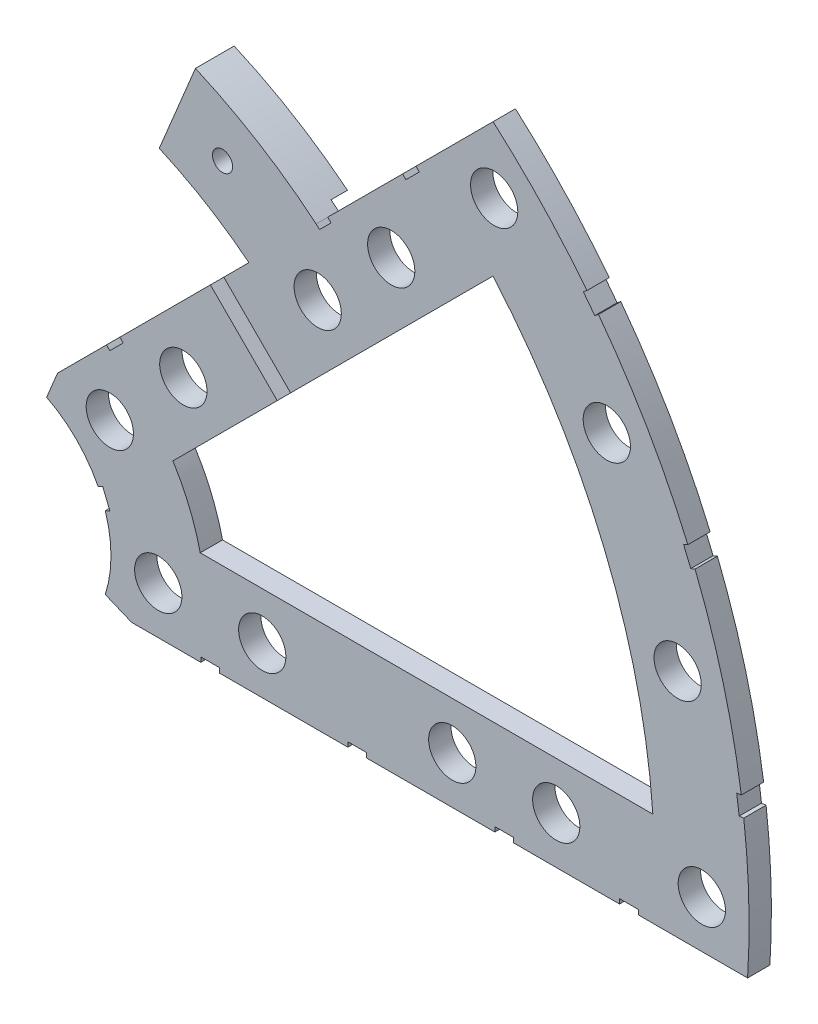
from build123d import *

# Parameters (mm, degrees)
BOSS_EXTRUDE1_DEPTH   = 3.000000096
SKETCH2_R             = 3.175
CUT_EXTRUDE1_DEPTH    = 4.000000096
SKETCH3_W             = 2.54
SKETCH3_H             = 0.635
CUT_EXTRUDE2_DEPTH    = 4.000000096
BOSS_EXTRUDE2_DEPTH   = 2.206999904
F_6_32_TAPPED_HOLE1_D = 2.7051


with BuildPart() as part:
    # Sketch1 → Boss-Extrude1 (new body)
    with BuildSketch(Plane.XY):
        with BuildLine():
            Line((22.357699804, 50.65759216), (27.218819563, 62.393373411))
            ThreePointArc((27.218819563, 62.393373411), (35.677104191, 57.973626939), (43.43415954, 52.414415661))
            Line((43.43415954, 52.414415661), (67.21146711, 76.191723231))
            ThreePointArc((67.21146711, 76.191723231), (93.866160503, 38.880636728), (101.401368334, -6.35))
            Line((101.401368334, -6.35), (18.648926052, -6.35))
            Line((18.648926052, -6.35), (15.105587123, -4.88230096))
            ThreePointArc((15.105587123, -4.88230096), (14.666587579, 6.075099489), (7.228954972, 14.133571205))
            Line((7.228954972, 14.133571205), (8.696654013, 17.676910134))
            Line((8.696654013, 17.676910134), (34.405475059, 43.38573118))
            ThreePointArc((34.405475059, 43.38573118), (28.61353693, 47.405947816), (22.357699804, 50.65759216))
        make_face()
        with BuildLine():
            Line((88.672924278, 6.35), (27.86051193, 6.35))
            ThreePointArc((27.86051193, 6.35), (26.399857642, 10.93517908), (24.190484974, 15.210228852))
            Line((24.190484974, 15.210228852), (67.191354125, 58.211098004))
            ThreePointArc((67.191354125, 58.211098004), (82.13289044, 34.020557137), (88.672924278, 6.35))
        make_face(mode=Mode.SUBTRACT)
    extrude(amount=BOSS_EXTRUDE1_DEPTH)

    # Sketch2 → Cut-Extrude1 (cut, through all)
    with BuildSketch(Plane.XY.offset(3.000000096)):
        with Locations((22.225, 0)):
            Circle(SKETCH2_R)
        with Locations((36.195, 0)):
            Circle(SKETCH2_R)
        with Locations((61.722, 0)):
            Circle(SKETCH2_R)
        with Locations((75.692, 0)):
            Circle(SKETCH2_R)
        with Locations((95.25, 0)):
            Circle(SKETCH2_R)
        with Locations((15.715448212, 15.715448212)):
            Circle(SKETCH2_R)
        with Locations((25.593729945, 25.593729945)):
            Circle(SKETCH2_R)
        with Locations((43.644044748, 43.644044748)):
            Circle(SKETCH2_R)
        with Locations((53.522326482, 53.522326482)):
            Circle(SKETCH2_R)
        with Locations((92.004434954, 24.652514046)):
            Circle(SKETCH2_R)
        with Locations((82.48891971, 47.625)):
            Circle(SKETCH2_R)
        with Locations((67.351920908, 67.351920908)):
            Circle(SKETCH2_R)
    extrude(amount=-CUT_EXTRUDE1_DEPTH, mode=Mode.SUBTRACT)

    # Sketch3 → Cut-Extrude2 (cut, through all)
    with BuildSketch(Plane.XY.offset(3.000000096)):
        Polygon((15.266435406, 24.246691527), (17.06248663, 26.042742751), (17.511499436, 25.593729945), (15.715448212, 23.797678721), align=None)
        Polygon((44.991083167, 53.971339288), (43.43415954, 52.414415661), (43.883172346, 51.965402855), (45.440095973, 53.522326482), align=None)
        with Locations((29.21, -6.0325)):
            Rectangle(SKETCH3_W, SKETCH3_H)
        with Locations((68.707, -6.0325)):
            Rectangle(SKETCH3_W, SKETCH3_H)
        Polygon((29.230733674, 38.210989795), (31.026784898, 40.007041019), (40.007041019, 31.026784898), (38.210989795, 29.230733674), align=None)
        Polygon((56.845021246, 65.825277367), (55.048970022, 64.029226143), (55.497982828, 63.580213337), (57.294034052, 65.376264561), align=None)
        with Locations((48.9585, -6.0325)):
            Rectangle(SKETCH3_W, SKETCH3_H)
        with Locations((85.471, -6.0325)):
            Rectangle(SKETCH3_W, SKETCH3_H)
        Polygon((99.935462164, 14.437711971), (100.266998693, 11.919442024), (101.526133667, 12.085210288), (101.194597138, 14.603480236), align=None)
        Polygon((93.765504959, 37.464305742), (94.938831965, 37.950313702), (93.966816047, 40.296967714), (92.793489041, 39.810959755), align=None)
        Polygon((79.327792988, 62.471156422), (80.874047017, 60.456038938), (81.88160576, 61.229165953), (80.33535173, 63.244283437), align=None)
        Polygon((13.593916116, 7.005422516), (14.565932035, 4.658768503), (15.739259041, 5.144776462), (14.767243123, 7.491430475), align=None)
    extrude(amount=-CUT_EXTRUDE2_DEPTH, mode=Mode.SUBTRACT)

    # Sketch4 → Boss-Extrude2 (add)
    with BuildSketch(Plane(origin=(0, 0, 0), x_dir=(-1, 0, 0), z_dir=(0, 0, -1))):
        with BuildLine():
            Line((-27.218819563, 62.393373411), (-22.357699804, 50.65759216))
            ThreePointArc((-22.357699804, 50.65759216), (-28.063600293, 47.73355971), (-33.393246405, 44.169553751))
            Line((-33.393246405, 44.169553751), (-42.443492672, 53.219800017))
            ThreePointArc((-42.443492672, 53.219800017), (-35.13186657, 58.305652688), (-27.218819563, 62.393373411))
        make_face()
    extrude(amount=BOSS_EXTRUDE2_DEPTH)

    # #6-32 Tapped Hole1 (through all)
    with Locations(Plane.XY.offset(3.000000096)):
        with Locations((30.861, 53.452819972)):
            Hole(F_6_32_TAPPED_HOLE1_D / 2)


solid = part.part
